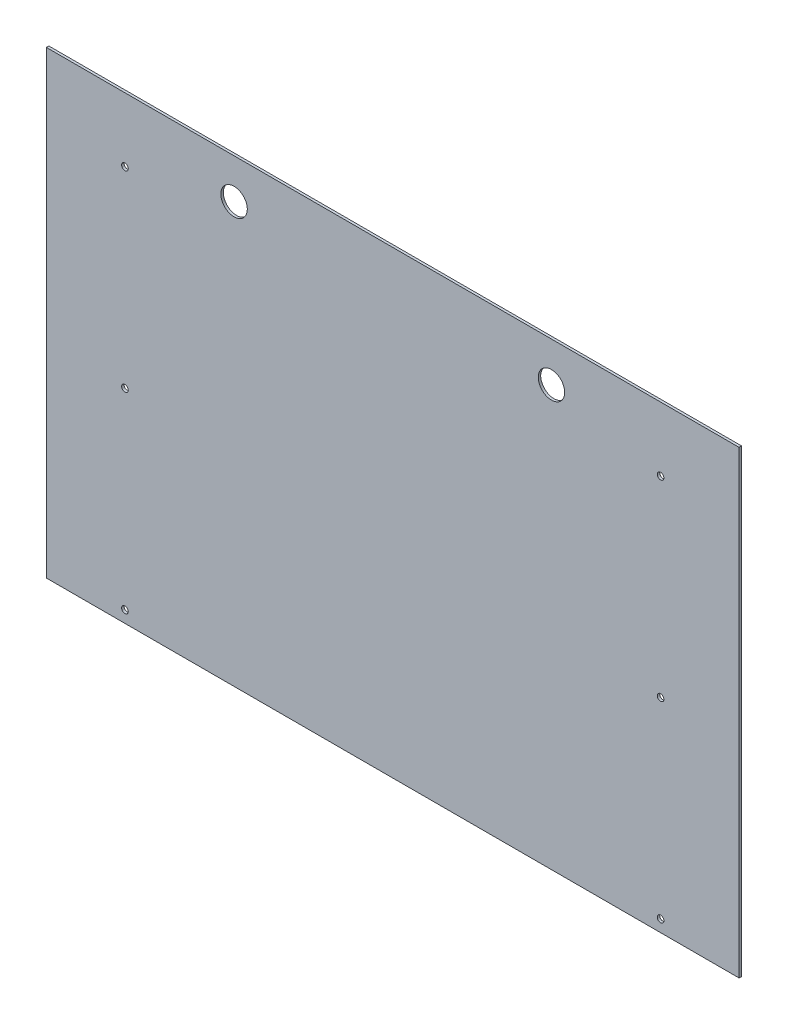
from build123d import *

# Parameters (mm, degrees)
SKETCH1_W          = 1330.325
SKETCH1_H          = 882.65
EXTRUDE1_DEPTH     = 4.7625
SKETCH2_R          = 6.35
CUT_EXTRUDE1_DEPTH = 5.7625
SKETCH3_R          = 25.4
CUT_EXTRUDE2_DEPTH = 5.7625


with BuildPart() as part:
    # Sketch1 → Extrude1 (new body)
    with BuildSketch(Plane.XY):
        with Locations((0, 638.175)):
            Rectangle(SKETCH1_W, SKETCH1_H)
    extrude(amount=EXTRUDE1_DEPTH)

    # Sketch2 → Cut-Extrude1 (cut, through all)
    with BuildSketch(Plane.XY.offset(4.7625)):
        with Locations((514.35, 956.31)):
            Circle(SKETCH2_R)
        with Locations((514.35, 588.01)):
            Circle(SKETCH2_R)
        with Locations((514.35, 219.71)):
            Circle(SKETCH2_R)
        with Locations((-514.35, 219.71)):
            Circle(SKETCH2_R)
        with Locations((-514.35, 588.01)):
            Circle(SKETCH2_R)
        with Locations((-514.35, 956.31)):
            Circle(SKETCH2_R)
    extrude(amount=-CUT_EXTRUDE1_DEPTH, mode=Mode.SUBTRACT)

    # Sketch3 → Cut-Extrude2 (cut, through all)
    with BuildSketch(Plane.XY.offset(4.7625)):
        with Locations((304.8, 1003.3)):
            Circle(SKETCH3_R)
        with Locations((-304.8, 1003.3)):
            Circle(SKETCH3_R)
    extrude(amount=-CUT_EXTRUDE2_DEPTH, mode=Mode.SUBTRACT)


solid = part.part
